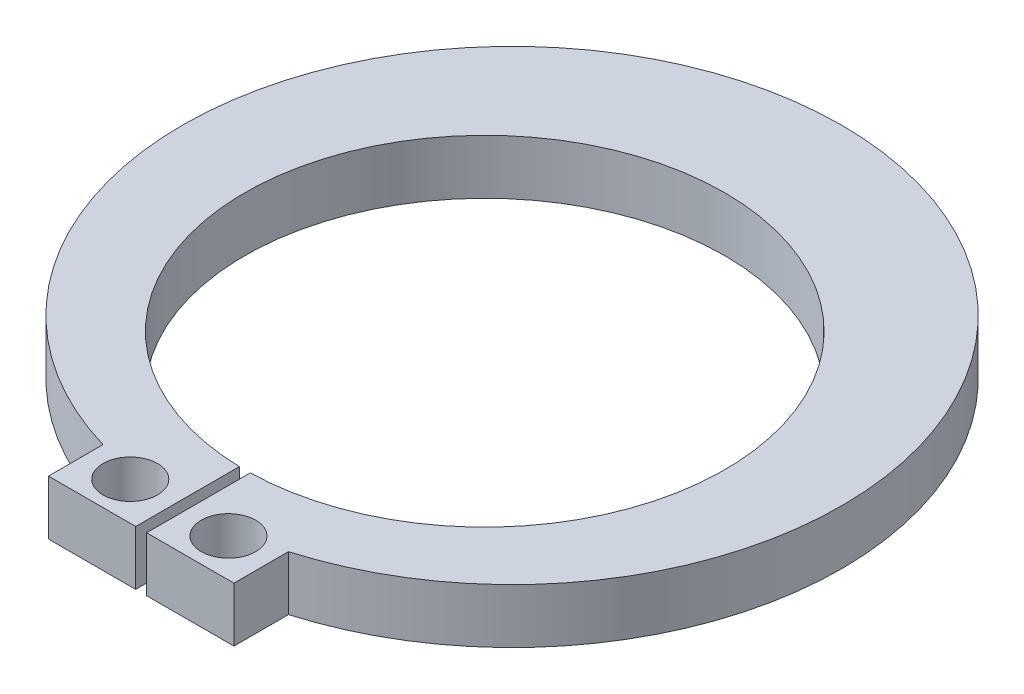
from build123d import *

# Parameters (mm, degrees)
SKETCH1_R           = 0.5
BOSS_EXTRUDE1_DEPTH = 1


with BuildPart() as part:
    # Sketch1 → Boss-Extrude1 (new body)
    with BuildSketch(Plane(origin=(0, 0, 0), x_dir=(1, 0, 0), z_dir=(0, 1, 0))):
        with BuildLine():
            Line((-1.7, -6.8), (-0.1, -6.8))
            Line((-0.1, -6.8), (-0.1, -4.89886349))
            ThreePointArc((-0.1, -4.89886349), (0, 3.9), (0.1, -4.89886349))
            Line((0.1, -4.89886349), (0.1, -6.8))
            Line((0.1, -6.8), (1.7, -6.8))
            Line((1.7, -6.8), (1.7, -5.8))
            ThreePointArc((1.7, -5.8), (0, 6.044005295), (-1.7, -5.8))
            Line((-1.7, -5.8), (-1.7, -6.8))
        make_face()
        with Locations((-0.9, -6.1)):
            Circle(SKETCH1_R, mode=Mode.SUBTRACT)
        with Locations((0.9, -6.1)):
            Circle(SKETCH1_R, mode=Mode.SUBTRACT)
    extrude(amount=BOSS_EXTRUDE1_DEPTH)


solid = part.part
